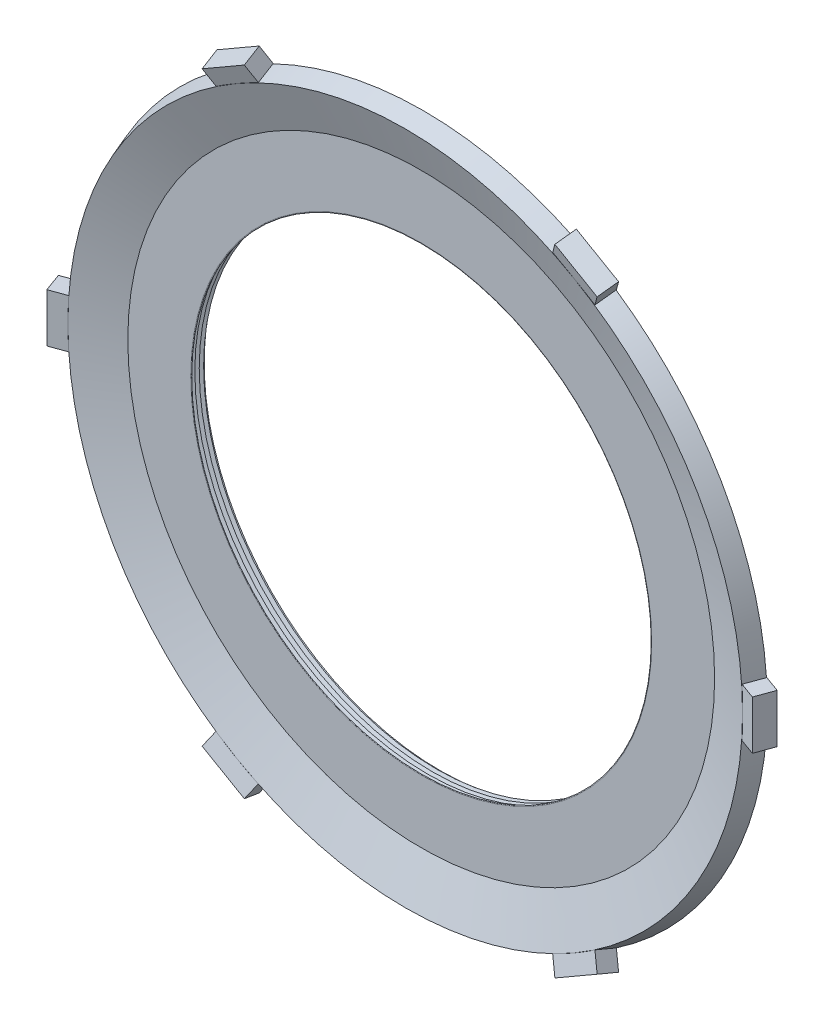
from build123d import *

# Parameters (mm, degrees)
EXTRUDE3_DEPTH    = 2.54
CIRPATTERN1_COUNT = 6
FILLET4_R         = 0.127
LPATTERN1_COUNT   = 5
LPATTERN1_PITCH   = 0.4572


with BuildPart() as part:
    # Sketch1 → Revolve1 (revolve)
    with BuildSketch(Plane(origin=(0, 0, 0), x_dir=(1, 0, 0), z_dir=(0, 1, 0)), mode=Mode.PRIVATE) as revolve1_sk:
        Polygon((23.876, 2.032), (31.242, 2.032), (35.814, 0.367928089), (35.12539449, -1.524), (30.55339449, 0.140071911), (23.876, 0.140071911), align=None)
    revolve(revolve1_sk.sketch.rotate(Axis((0, 0, -37.83814433), (0, 0, 1)), 180), axis=Axis((0, 0, -37.83814433), (0, 0, 1)))  # turned: the seam where the file's is

    # Sketch3 → Extrude3 (add, symmetric)
    with BuildSketch(Plane(origin=(0, 0, 0), x_dir=(1, 0, 0), z_dir=(0, 1, 0))):
        Polygon((34.798, 0.737721847), (37.423501182, -0.217882434), (36.734895673, -2.109810522), (34.10939449, -1.154206242), align=None)
    extrude3 = extrude(amount=EXTRUDE3_DEPTH, both=True)

    # CirPattern1: Extrude3 ×6 about axis
    cirpattern1_axis = Axis((0, 0, 0), (0, 0, 1))
    for i in range(1, CIRPATTERN1_COUNT):
        add(extrude3.rotate(cirpattern1_axis, i * 360 / CIRPATTERN1_COUNT))

    # Fillet4
    fillet4_edges = [part.edges().sort_by_distance(p)[0] for p in [
        (23.876, 0, -0.140071911),
        (23.876, 0, -2.032),
    ]]
    fillet(fillet4_edges, radius=FILLET4_R)

    # Sketch4 → Cut-Revolve1 (revolve, cut)
    with BuildSketch(Plane(origin=(0, 0, 0), x_dir=(1, 0, 0), z_dir=(0, 1, 0))):
        Polygon((-23.876, 0.140071911), (-23.876, 1.019953721), (-24.638, 0.580012816), align=None)
    cut_revolve1 = revolve(axis=Axis((0, 0, -37.83814433), (0, 0, 1)), mode=Mode.SUBTRACT)

    # LPattern1: Cut-Revolve1 ×5
    with Locations(*[(0, 0, -i * LPATTERN1_PITCH) for i in range(1, LPATTERN1_COUNT)]):
        add(cut_revolve1, mode=Mode.SUBTRACT)


solid = part.part
